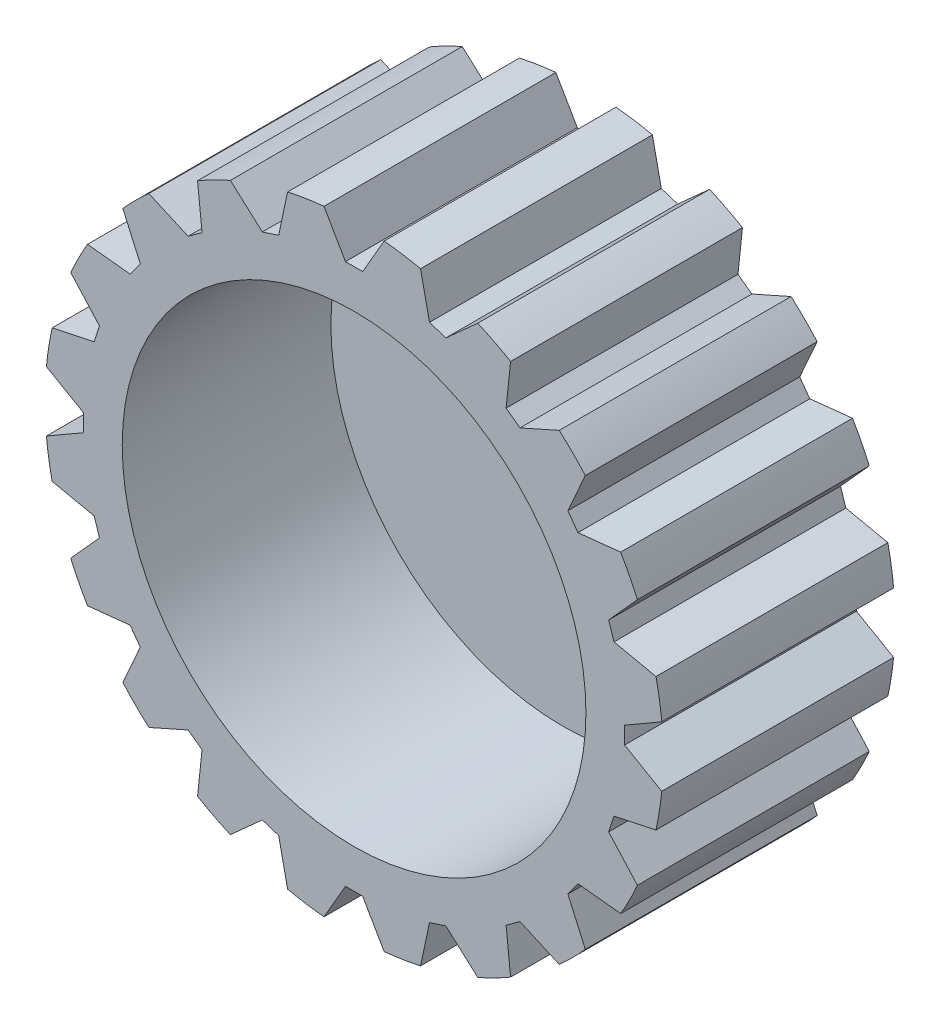
from build123d import *

# Parameters (mm, degrees)
SKETCH1_R           = 40
BOSS_EXTRUDE1_DEPTH = 30
CUT_EXTRUDE1_DEPTH  = 30
SKETCH3_R           = 30
CUT_EXTRUDE2_DEPTH  = 27
SKETCH4_R           = 1.5
SKETCH4_R_2         = 3.5
CUT_EXTRUDE3_DEPTH  = 27


with BuildPart() as part:
    # Sketch1 → Boss-Extrude1 (new body)
    with BuildSketch(Plane.XY):
        Circle(SKETCH1_R)
    extrude(amount=BOSS_EXTRUDE1_DEPTH)

    # Sketch2 → Cut-Extrude1 (cut)
    with BuildSketch(Plane.XY.offset(30)):
        Polygon((4, 40), (-4, 40), (-1.113248654, 35), (1.113248654, 35), align=None)
        Polygon((11.87435719, 32.942965317), (16.16490584, 36.806192674), (8.55645371, 39.278328629), (9.756832416, 33.630990823), align=None)
        Polygon((21.47312091, 27.661243662), (26.747478069, 30.009538766), (20.275342114, 34.711820784), (19.67184675, 28.969945944), align=None)
        Polygon((28.969945944, 19.67184675), (34.711820784, 20.275342114), (30.009538766, 26.747478069), (27.661243662, 21.47312091), align=None)
        Polygon((33.630990823, 9.756832416), (39.278328629, 8.55645371), (36.806192674, 16.16490584), (32.942965317, 11.87435719), align=None)
        Polygon((35, -1.113248654), (40, -4), (40, 4), (35, 1.113248654), align=None)
        Polygon((32.942965317, -11.87435719), (36.806192674, -16.16490584), (39.278328629, -8.55645371), (33.630990823, -9.756832416), align=None)
        Polygon((27.661243662, -21.47312091), (30.009538766, -26.747478069), (34.711820784, -20.275342114), (28.969945944, -19.67184675), align=None)
        Polygon((19.67184675, -28.969945944), (20.275342114, -34.711820784), (26.747478069, -30.009538766), (21.47312091, -27.661243662), align=None)
        Polygon((9.756832416, -33.630990823), (8.55645371, -39.278328629), (16.16490584, -36.806192674), (11.87435719, -32.942965317), align=None)
        Polygon((-1.113248654, -35), (-4, -40), (4, -40), (1.113248654, -35), align=None)
        Polygon((-11.87435719, -32.942965317), (-16.16490584, -36.806192674), (-8.55645371, -39.278328629), (-9.756832416, -33.630990823), align=None)
        Polygon((-21.47312091, -27.661243662), (-26.747478069, -30.009538766), (-20.275342114, -34.711820784), (-19.67184675, -28.969945944), align=None)
        Polygon((-28.969945944, -19.67184675), (-34.711820784, -20.275342114), (-30.009538766, -26.747478069), (-27.661243662, -21.47312091), align=None)
        Polygon((-33.630990823, -9.756832416), (-39.278328629, -8.55645371), (-36.806192674, -16.16490584), (-32.942965317, -11.87435719), align=None)
        Polygon((-35, 1.113248654), (-40, 4), (-40, -4), (-35, -1.113248654), align=None)
        Polygon((-32.942965317, 11.87435719), (-36.806192674, 16.16490584), (-39.278328629, 8.55645371), (-33.630990823, 9.756832416), align=None)
        Polygon((-27.661243662, 21.47312091), (-30.009538766, 26.747478069), (-34.711820784, 20.275342114), (-28.969945944, 19.67184675), align=None)
        Polygon((-19.67184675, 28.969945944), (-20.275342114, 34.711820784), (-26.747478069, 30.009538766), (-21.47312091, 27.661243662), align=None)
        Polygon((-9.756832416, 33.630990823), (-8.55645371, 39.278328629), (-16.16490584, 36.806192674), (-11.87435719, 32.942965317), align=None)
    extrude(amount=-CUT_EXTRUDE1_DEPTH, mode=Mode.SUBTRACT)

    # Sketch3 → Cut-Extrude2 (cut)
    with BuildSketch(Plane.XY.offset(30)):
        Circle(SKETCH3_R)
    extrude(amount=-CUT_EXTRUDE2_DEPTH, mode=Mode.SUBTRACT)

    # Sketch4 → Cut-Extrude3 (cut)
    with BuildSketch(Plane.XY.offset(3)):
        with Locations((8.5, 0)):
            Circle(SKETCH4_R)
        with Locations((-8.5, 0)):
            Circle(SKETCH4_R)
        with Locations((0, -8.5)):
            Circle(SKETCH4_R)
        with Locations((0, 8.5)):
            Circle(SKETCH4_R)
        Circle(SKETCH4_R_2)
    extrude(amount=-CUT_EXTRUDE3_DEPTH, mode=Mode.SUBTRACT)


solid = part.part
